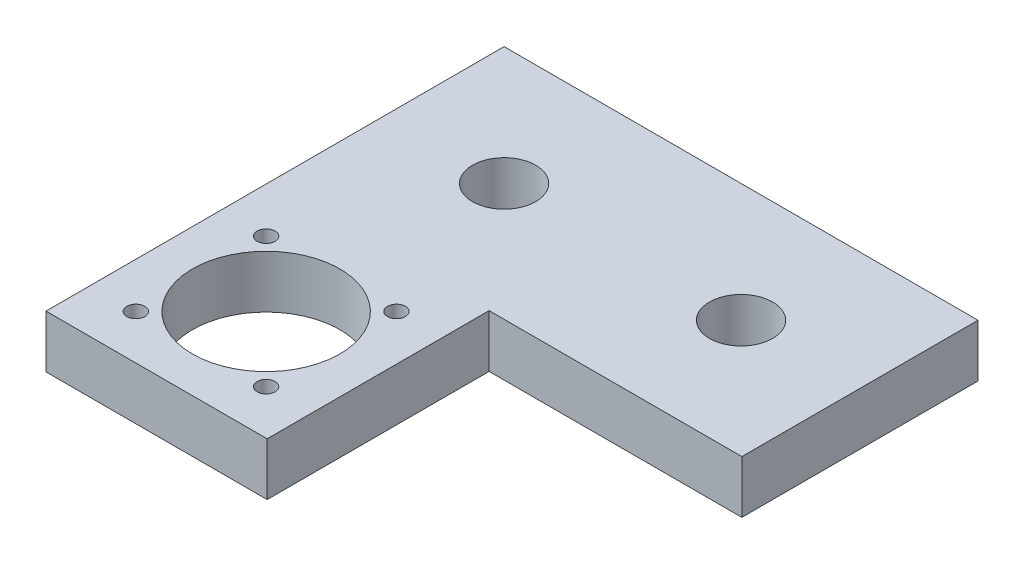
from build123d import *

# Parameters (mm, degrees)
EXTRUDE_1_DEPTH     = 10
SKETCH_2_R          = 6
CUT_EXTRUDE_1_DEPTH = 11
SKETCH_3_R          = 14
SKETCH_3_R_2        = 1.7
CUT_EXTRUDE_2_DEPTH = 11


with BuildPart() as part:
    # Эскиз1 → Бобышка-Вытянуть1 (new body)
    with BuildSketch(Plane(origin=(0, 0, 0), x_dir=(1, 0, 0), z_dir=(0, 1, 0))):
        Polygon((42, 0.149999792), (89.999875, 0.149999792), (89.999875, 45), (0, 45), (0, 0), (0, -42), (42, -42), align=None)
    extrude(amount=EXTRUDE_1_DEPTH)

    # Эскиз2 → Вырез-Вытянуть1 (cut, through all)
    with BuildSketch(Plane(origin=(0, 10, 0), x_dir=(1, 0, 0), z_dir=(0, 1, 0))):
        with Locations((67.5, 22.5)):
            Circle(SKETCH_2_R)
        with Locations((22.5, 22.5)):
            Circle(SKETCH_2_R)
    extrude(amount=-CUT_EXTRUDE_1_DEPTH, mode=Mode.SUBTRACT)

    # Эскиз3 → Вырез-Вытянуть2 (cut, through all)
    with BuildSketch(Plane(origin=(0, 10, 0), x_dir=(1, 0, 0), z_dir=(0, 1, 0))):
        with Locations((20.959394321, -21.15)):
            Circle(SKETCH_3_R)
        with Locations((33.333762992, -33.524368671)):
            Circle(SKETCH_3_R_2)
        with Locations((8.585025651, -33.524368671)):
            Circle(SKETCH_3_R_2)
        with Locations((8.585025651, -8.775631329)):
            Circle(SKETCH_3_R_2)
        with Locations((33.333762992, -8.775631329)):
            Circle(SKETCH_3_R_2)
    extrude(amount=-CUT_EXTRUDE_2_DEPTH, mode=Mode.SUBTRACT)


solid = part.part
